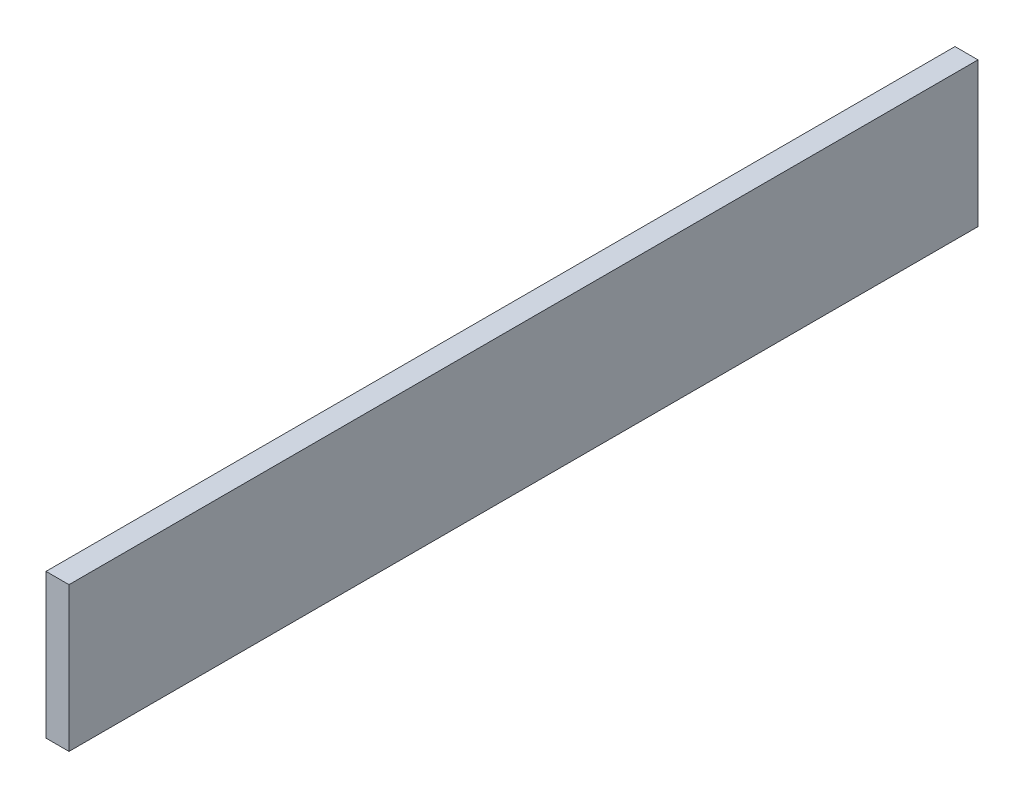
from build123d import *

# Parameters (mm, degrees)
SKETCH1_W           = 250.952
SKETCH1_H           = 39.878
BOSS_EXTRUDE1_DEPTH = 6.35


with BuildPart() as part:
    # Sketch1 → Boss-Extrude1 (new body)
    with BuildSketch(Plane(origin=(0, 0, 0), x_dir=(0, 0, -1), z_dir=(1, 0, 0))):
        Rectangle(SKETCH1_W, SKETCH1_H)
    extrude(amount=BOSS_EXTRUDE1_DEPTH)


solid = part.part
